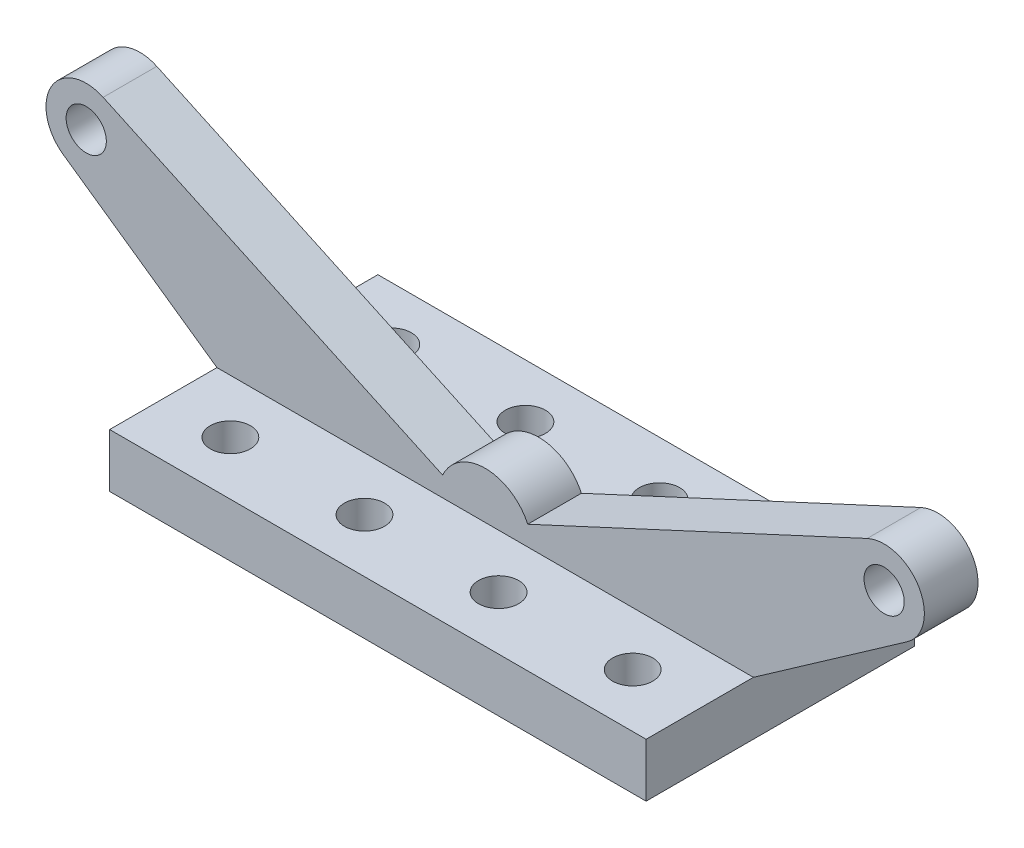
from build123d import *

# Parameters (mm, degrees)
SKETCH1_W           = 200
SKETCH1_H           = 100
BOSS_EXTRUDE1_DEPTH = 20
SKETCH2_R           = 7.5
CUT_EXTRUDE1_DEPTH  = 20
BOSS_EXTRUDE2_DEPTH = 10
SKETCH4_R           = 7.5
CUT_EXTRUDE2_DEPTH  = 20


with BuildPart() as part:
    # Sketch1 → Boss-Extrude1 (new body)
    with BuildSketch(Plane(origin=(0, 0, 0), x_dir=(1, 0, 0), z_dir=(0, 1, 0))):
        Rectangle(SKETCH1_W, SKETCH1_H)
    extrude(amount=BOSS_EXTRUDE1_DEPTH)

    # Sketch2 → Cut-Extrude1 (cut)
    with BuildSketch(Plane(origin=(0, 20, 0), x_dir=(1, 0, 0), z_dir=(0, 1, 0))):
        with Locations((-75, 30)):
            Circle(SKETCH2_R)
        with Locations((-25, 30)):
            Circle(SKETCH2_R)
        with Locations((25, 30)):
            Circle(SKETCH2_R)
        with Locations((75, 30)):
            Circle(SKETCH2_R)
        with Locations((-75, -30)):
            Circle(SKETCH2_R)
        with Locations((-25, -30)):
            Circle(SKETCH2_R)
        with Locations((25, -30)):
            Circle(SKETCH2_R)
        with Locations((75, -30)):
            Circle(SKETCH2_R)
    extrude(amount=-CUT_EXTRUDE1_DEPTH, mode=Mode.SUBTRACT)

    # Sketch3 → Boss-Extrude2 (add, symmetric)
    with BuildSketch(Plane.XY):
        with BuildLine():
            Line((-100, 20), (100, 20))
            Line((100, 20), (157.3406431, 60.150350545))
            ThreePointArc((157.3406431, 60.150350545), (161.735357089, 79.923793338), (142.426691144, 86.045718717))
            Line((142.426691144, 86.045718717), (15.876102092, 27.36202298))
            ThreePointArc((15.876102092, 27.36202298), (0, 37.5), (-15.876102092, 27.36202298))
            Line((-15.876102092, 27.36202298), (-142.426691144, 86.045718717))
            ThreePointArc((-142.426691144, 86.045718717), (-161.735357089, 79.923793338), (-157.3406431, 60.150350545))
            Line((-157.3406431, 60.150350545), (-100, 20))
        make_face()
    extrude(amount=BOSS_EXTRUDE2_DEPTH, both=True)

    # Sketch4 → Cut-Extrude2 (cut)
    with BuildSketch(Plane.XY.offset(10)):
        with Locations((148.736996555, 72.437631209)):
            Circle(SKETCH4_R)
        with Locations((-148.736996555, 72.437631209)):
            Circle(SKETCH4_R)
    extrude(amount=-CUT_EXTRUDE2_DEPTH, mode=Mode.SUBTRACT)


solid = part.part
